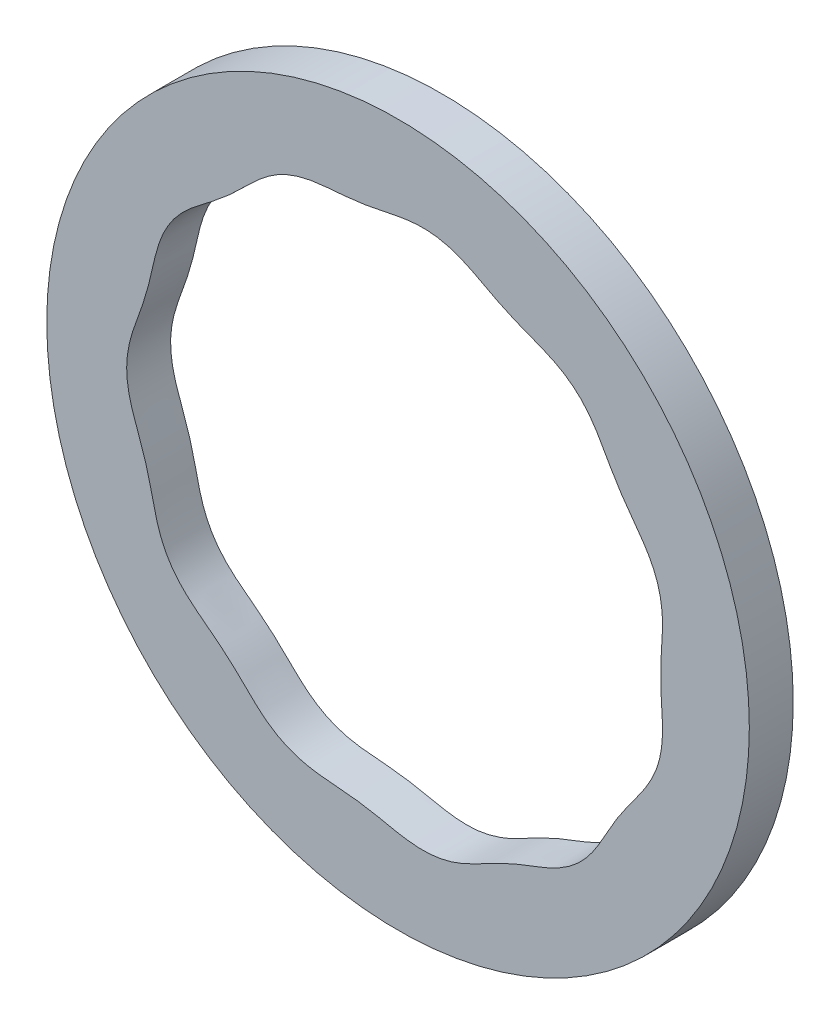
from build123d import *

# Parameters (mm, degrees)
SKETCH2_R           = 40
BOSS_EXTRUDE1_DEPTH = 5
CUT_EXTRUDE1_DEPTH  = 6


with BuildPart() as part:
    # Sketch2 → Boss-Extrude1 (new body)
    with BuildSketch(Plane.XY):
        Circle(SKETCH2_R)
    extrude(amount=BOSS_EXTRUDE1_DEPTH)

    # Sketch3 → Cut-Extrude1 (cut, through all)
    with BuildSketch(Plane.XY):
        with BuildLine():
            add(Edge.make_bspline(
                [(-28.694491148, -8.404591673), (-28.551956047, -8.888814094), (-28.422066204, -9.376706881), (-28.180644968, -10.357821109), (-28.06953522, -10.851164936), (-27.734296048, -12.330642048), (-27.50669041, -13.31576634), (-27.003191047, -14.746404877), (-26.808757163, -15.21599184), (-26.351397553, -16.133552052), (-26.094315725, -16.570164898), (-25.524029186, -17.399587705), (-25.210781796, -17.792364356), (-24.533820102, -18.538529153), (-24.169732903, -18.891963171), (-23.022622406, -19.907382016), (-22.197035369, -20.514083512), (-20.979550037, -21.448258221), (-20.577090062, -21.763538515), (-19.788404888, -22.412841319), (-19.402312426, -22.747017067), (-18.646306819, -23.434046755), (-18.276674024, -23.787224344), (-17.544264679, -24.501494706), (-17.181628125, -24.862749097), (-16.445709768, -25.572968484), (-16.071378808, -25.922093427), (-15.297010645, -26.582751337), (-14.89703551, -26.893793538), (-14.061766079, -27.462622601), (-13.626485442, -27.720430056), (-12.715494223, -28.175083424), (-12.238342948, -28.371704219), (-11.275030491, -28.692776454), (-10.785219167, -28.819453339), (-9.792510436, -29.018474841), (-9.289637125, -29.090919509), (-8.276388209, -29.204659983), (-7.767024635, -29.246241579), (-6.748605199, -29.327896781), (-6.239311855, -29.368134626), (-5.223542226, -29.468476893), (-4.717070014, -29.528610035), (-3.707838647, -29.675061665), (-3.205113792, -29.761622056), (-1.700940477, -30.04952098), (-0.704128732, -30.28355873), (0.804084235, -30.542969073), (1.309171839, -30.61286679), (2.327460888, -30.695441509), (2.835981052, -30.707512916), (3.844258567, -30.661977287), (4.345088709, -30.604907931), (5.339825953, -30.418995693), (5.836999598, -30.288874645), (7.286308199, -29.809543148), (8.198806027, -29.368770777), (9.546842647, -28.660869745), (9.993323642, -28.418437495), (10.890645249, -27.943412589), (11.34181602, -27.711565101), (12.254091956, -27.270291922), (12.715274165, -27.061040119), (13.647514901, -26.664827231), (14.118488494, -26.477674453), (15.537472184, -25.92990003), (16.491340199, -25.582499628), (17.866918332, -24.936759432), (18.314817644, -24.700751006), (19.170999967, -24.178164027), (19.580682552, -23.891148819), (20.164249198, -23.417370457), (20.353729024, -23.252398765), (20.722197324, -22.907796152), (20.901984417, -22.727481156), (21.419479572, -22.171335251), (21.735476876, -21.781272333), (22.615467704, -20.565829237), (23.109574935, -19.693940125), (23.841730997, -18.380113822), (24.085080794, -17.941704396), (24.586833133, -17.07490306), (24.845487704, -16.646678874), (25.384076544, -15.804392022), (25.664003327, -15.390324375), (26.24010817, -14.573004213), (26.536395437, -14.169824375), (27.425901987, -12.96071394), (28.01802871, -12.154056249), (28.772409554, -10.855020415), (28.999240708, -10.412124622), (29.390716185, -9.505159525), (29.555887957, -9.040755595), (29.821358491, -8.088768267), (29.921883597, -7.599181329), (30.058898707, -6.606408449), (30.094880388, -6.108819266), (30.130960118, -4.613394281), (30.058841889, -3.613020224), (29.965432522, -2.11441034), (29.937139822, -1.61477807), (29.902480657, -0.614776094), (29.896177278, -0.114404267), (29.908686272, 0.887184094), (29.927642421, 1.388405463), (29.980871931, 2.391363358), (30.015078882, 2.89309765), (30.105834806, 4.397901478), (30.146167145, 5.400425609), (30.02683858, 6.898163764), (29.957833753, 7.396426782), (29.747863503, 8.390532602), (29.604400303, 8.89126074), (29.080859326, 10.324522848), (28.603665961, 11.202774569), (27.508903147, 12.874661655), (26.896490573, 13.671405498), (26.014830404, 14.888799343), (25.726737234, 15.298089549), (25.171689464, 16.129411936), (24.904784479, 16.551474025), (24.390605323, 17.40743133), (24.143244955, 17.841262036), (23.655147878, 18.713397408), (23.414301954, 19.151525109), (22.668474371, 20.450927527), (22.136417119, 21.294786434), (21.331952026, 22.25994809), (21.163608206, 22.449423711), (20.816463415, 22.814214563), (20.637746156, 22.989560975), (20.086183954, 23.494486278), (19.697770641, 23.802734834), (18.882052677, 24.36594665), (18.454616946, 24.620730314), (17.56733741, 25.085895111), (17.107533296, 25.295885174), (16.178249819, 25.686223467), (15.707268541, 25.867503486), (14.764544398, 26.22839499), (14.29288574, 26.408190957), (13.357487118, 26.785131745), (12.893784205, 26.982357739), (11.97712541, 27.400355105), (11.524179427, 27.621148164), (10.626468944, 28.080658874), (10.181550563, 28.31903939), (9.291527215, 28.795391636), (8.846139077, 29.032742974), (7.943216742, 29.480835179), (7.486113535, 29.690466878), (6.556453791, 30.057949259), (6.083493528, 30.216015003), (5.117386793, 30.468399266), (4.622374624, 30.56276555), (3.617951471, 30.680601733), (3.117375803, 30.70315036), (2.119052577, 30.685373127), (1.621315331, 30.644818029), (0.627925625, 30.517358929), (0.131891859, 30.430624753), (-0.85709638, 30.237322199), (-1.35026981, 30.131567543), (-2.337713143, 29.927616102), (-2.832032449, 29.829759855), (-3.823970216, 29.656788102), (-4.321642615, 29.582044387), (-5.320570131, 29.457252275), (-5.821801955, 29.407043317), (-7.328437494, 29.276682046), (-8.336816146, 29.217035672), (-9.832352369, 29.01016792), (-10.330081299, 28.92058167), (-11.304794706, 28.683121487), (-11.781148766, 28.535981201), (-12.708909536, 28.177283467), (-13.160385215, 27.965904106), (-13.818665474, 27.599947036), (-14.035566694, 27.4693271), (-14.457726029, 27.196186184), (-14.663492725, 27.053354159), (-15.669027114, 26.311735038), (-16.396363784, 25.627584837), (-17.468548298, 24.579178767), (-17.823303219, 24.22659882), (-18.542799081, 23.533207886), (-18.907359242, 23.19218384), (-19.652553326, 22.529079376), (-20.033350866, 22.207191787), (-20.809096841, 21.580094055), (-21.204028027, 21.274863582), (-22.394734047, 20.366140258), (-23.19547933, 19.768505297), (-24.304402592, 18.763397438), (-24.659597174, 18.408744595), (-25.315343097, 17.664516512), (-25.617331976, 17.273932202), (-26.165568863, 16.452988218), (-26.411745829, 16.02257785), (-26.849034096, 15.12246356), (-27.036048036, 14.660850074), (-27.521052491, 13.257219286), (-27.743188042, 12.291976651), (-28.071400256, 10.842658344), (-28.180483183, 10.359458664), (-28.416534153, 9.398270828), (-28.54349288, 8.920279958), (-28.821300146, 7.971259442), (-28.972266469, 7.500264119), (-29.292409882, 6.563579887), (-29.461507012, 6.097867679), (-29.969370138, 4.700897654), (-30.306127138, 3.769054437), (-30.661101661, 2.32753437), (-30.754955849, 1.839897204), (-30.847234011, 1.094308185), (-30.869630496, 0.844775335), (-30.89705389, 0.351944878), (-30.902210877, 0.107436965), (-30.886878342, -1.105935247), (-30.74025976, -2.046678429), (-30.265024435, -3.887587373), (-29.937653446, -4.788030883), (-29.446676638, -6.138713911), (-29.283480944, -6.589044869), (-29.05193113, -7.267494063), (-28.97674657, -7.494089417), (-28.867950571, -7.834869998), (-28.832332648, -7.948607868), (-28.7798606, -8.119427559), (-28.762556256, -8.176409001), (-28.736838517, -8.2619344), (-28.728310534, -8.29045281), (-28.711332245, -8.347506948), (-28.703399592, -8.374327772), (-28.694491148, -8.404591673)],
                knots=[0, 0, 0, 0, 0.0078125, 0.0078125, 0.015625, 0.015625, 0.03125, 0.03125, 0.0390625, 0.0390625, 0.046875, 0.046875, 0.0546875, 0.0546875, 0.0625, 0.0625, 0.078125, 0.078125, 0.0859375, 0.0859375, 0.09375, 0.09375, 0.1015625, 0.1015625, 0.109375, 0.109375, 0.1171875, 0.1171875, 0.125, 0.125, 0.1328125, 0.1328125, 0.140625, 0.140625, 0.1484375, 0.1484375, 0.15625, 0.15625, 0.1640625, 0.1640625, 0.171875, 0.171875, 0.1796875, 0.1796875, 0.1875, 0.1875, 0.203125, 0.203125, 0.2109375, 0.2109375, 0.21875, 0.21875, 0.2265625, 0.2265625, 0.234375, 0.234375, 0.25, 0.25, 0.2578125, 0.2578125, 0.265625, 0.265625, 0.2734375, 0.2734375, 0.28125, 0.28125, 0.296875, 0.296875, 0.3046875, 0.3046875, 0.3125, 0.3125, 0.31640625, 0.31640625, 0.3203125, 0.3203125, 0.328125, 0.328125, 0.34375, 0.34375, 0.3515625, 0.3515625, 0.359375, 0.359375, 0.3671875, 0.3671875, 0.375, 0.375, 0.390625, 0.390625, 0.3984375, 0.3984375, 0.40625, 0.40625, 0.4140625, 0.4140625, 0.421875, 0.421875, 0.4375, 0.4375, 0.4453125, 0.4453125, 0.453125, 0.453125, 0.4609375, 0.4609375, 0.46875, 0.46875, 0.484375, 0.484375, 0.4921875, 0.4921875, 0.5, 0.5, 0.515625, 0.515625, 0.53125, 0.53125, 0.5390625, 0.5390625, 0.546875, 0.546875, 0.5546875, 0.5546875, 0.5625, 0.5625, 0.578125, 0.578125, 0.58203125, 0.58203125, 0.5859375, 0.5859375, 0.59375, 0.59375, 0.6015625, 0.6015625, 0.609375, 0.609375, 0.6171875, 0.6171875, 0.625, 0.625, 0.6328125, 0.6328125, 0.640625, 0.640625, 0.6484375, 0.6484375, 0.65625, 0.65625, 0.6640625, 0.6640625, 0.671875, 0.671875, 0.6796875, 0.6796875, 0.6875, 0.6875, 0.6953125, 0.6953125, 0.703125, 0.703125, 0.7109375, 0.7109375, 0.71875, 0.71875, 0.7265625, 0.7265625, 0.734375, 0.734375, 0.75, 0.75, 0.7578125, 0.7578125, 0.765625, 0.765625, 0.7734375, 0.7734375, 0.77734375, 0.77734375, 0.78125, 0.78125, 0.796875, 0.796875, 0.8046875, 0.8046875, 0.8125, 0.8125, 0.8203125, 0.8203125, 0.828125, 0.828125, 0.84375, 0.84375, 0.8515625, 0.8515625, 0.859375, 0.859375, 0.8671875, 0.8671875, 0.875, 0.875, 0.890625, 0.890625, 0.8984375, 0.8984375, 0.90625, 0.90625, 0.9140625, 0.9140625, 0.921875, 0.921875, 0.9375, 0.9375, 0.9453125, 0.9453125, 0.94921875, 0.94921875, 0.953125, 0.953125, 0.96875, 0.96875, 0.984375, 0.984375, 0.9921875, 0.9921875, 0.99609375, 0.99609375, 0.998046875, 0.998046875, 0.999023438, 0.999023438, 0.999511719, 0.999511719, 1, 1, 1, 1], degree=3))
        make_face()
    extrude(amount=CUT_EXTRUDE1_DEPTH, mode=Mode.SUBTRACT)


solid = part.part
